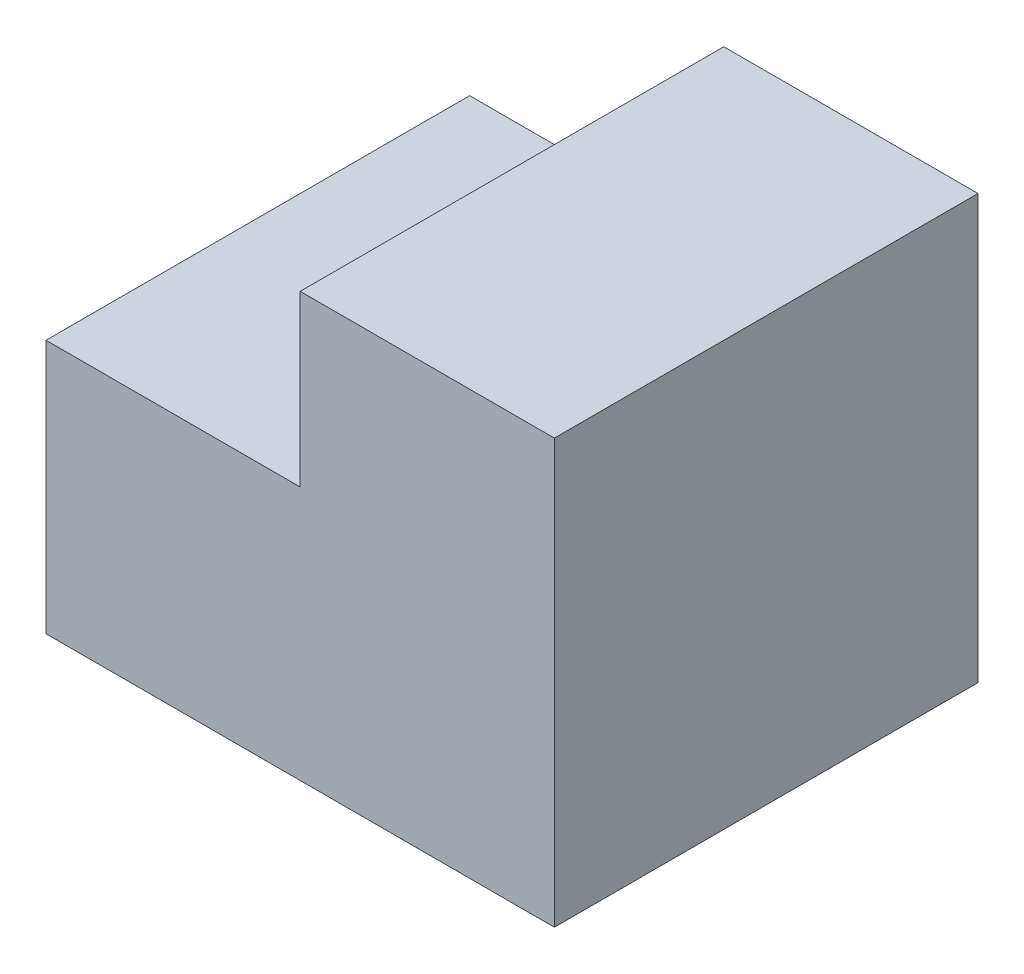
from build123d import *

# Parameters (mm, degrees)
BOSS_EXTRUDE1_DEPTH = 25


with BuildPart() as part:
    # Sketch1 → Boss-Extrude1 (new body)
    with BuildSketch(Plane.XY):
        Polygon((-30, 0), (0, 0), (0, 25), (-15, 25), (-15, 15), (-30, 15), align=None)
    extrude(amount=BOSS_EXTRUDE1_DEPTH)


solid = part.part
